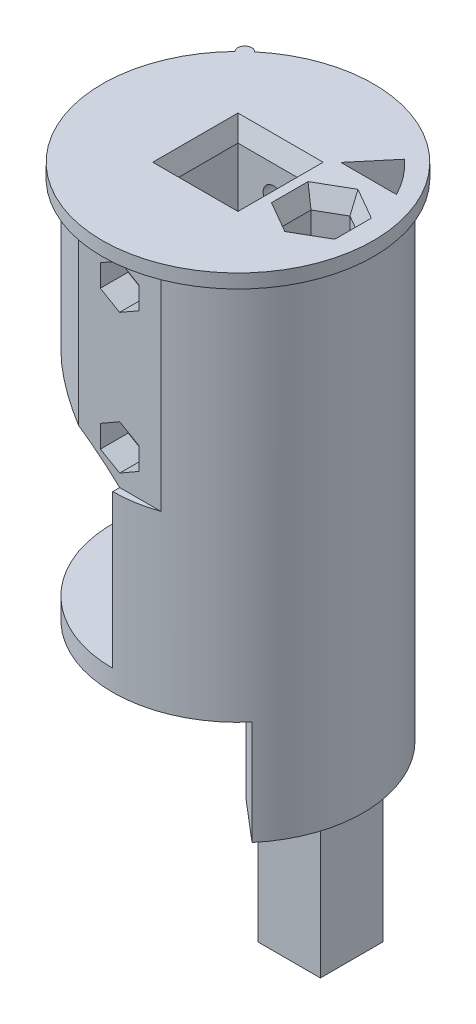
from build123d import *
from build123d.topology import SkipClean

# Parameters (mm, degrees)
SKETCH_1_R          = 18
EXTRUDE_1_DEPTH     = 55
SKETCH_2_R          = 19.5
EXTRUDE_2_DEPTH     = 2
SKETCH_3_W          = 10.25
SKETCH_3_H          = 10.25
CUT_EXTRUDE_1_DEPTH = 40
EXTRUDE_START       = 15
EXTRUDE_3_DEPTH     = 15
BOSS_EXTRUDE1_START = 20
SKETCH1_R           = 18
BOSS_EXTRUDE1_DEPTH = 20
BOSS_EXTRUDE2_START = 7
SKETCH3_R           = 18
BOSS_EXTRUDE2_DEPTH = 7
SKETCH4_W           = 10.2
SKETCH4_H           = 10.2
CUT_EXTRUDE2_DEPTH  = 27
CUT_EXTRUDE4_DEPTH  = 25
BOSS_EXTRUDE3_DEPTH = 3
SKETCH9_W           = 36
SKETCH9_H           = 22
CUT_EXTRUDE5_DEPTH  = 8
SKETCH10_R          = 3.7
SKETCH10_W          = 3
SKETCH10_H          = 2
CUT_EXTRUDE6_DEPTH  = 10
SKETCH11_R          = 2
CUT_EXTRUDE7_DEPTH  = 102
SKETCH15_R          = 18
CUT_EXTRUDE9_DEPTH  = 27
CUT_EXTRUDE11_DEPTH = 30
SKETCH18_R          = 1.5
CUT_EXTRUDE12_DEPTH = 71.437915926
SKETCH19_R          = 3
CUT_EXTRUDE13_DEPTH = 3
BOSS_EXTRUDE5_DEPTH = 22
CUT_EXTRUDE16_DEPTH = 4
CUT_EXTRUDE17_DEPTH = 25.4
CUT_EXTRUDE18_DEPTH = 71.437915926
FILLET2_R           = 5
SKETCH30_W          = 18.8
SKETCH30_H          = 10
CUT_EXTRUDE20_DEPTH = 3
CHAMFER1_SIZE       = 1
CHAMFER1_SIZE2      = 2.747477419
CHAMFER2_SIZE       = 1
CHAMFER2_SIZE2      = 2.747477419
BOSS_EXTRUDE7_START = 20
SKETCH37_W          = 9
SKETCH37_H          = 9
SKETCH37_R          = 2
BOSS_EXTRUDE7_DEPTH = 20
CUT_EXTRUDE22_DEPTH = 15
CUT_EXTRUDE23_DEPTH = 78.100583655
SKETCH40_W          = 4.363156696
SKETCH40_H          = 4.363156696
CUT_EXTRUDE24_DEPTH = 10
FILLET7_R           = 6
BOSS_EXTRUDE8_DEPTH = 2
CUT_EXTRUDE25_DEPTH = 12


with BuildPart() as part:
    # Эскиз1 → Бобышка-Вытянуть1 (new body)
    with BuildSketch(Plane(origin=(0, 0, 0), x_dir=(1, 0, 0), z_dir=(0, 1, 0))):
        with Locations(Location((0, 0, 0), (0, 0, 270))):
            Circle(SKETCH_1_R)
    extrude(amount=EXTRUDE_1_DEPTH)

    # Эскиз2 → Бобышка-Вытянуть2 (add)
    with BuildSketch(Plane(origin=(0, 55, 0), x_dir=(1, 0, 0), z_dir=(0, 1, 0))):
        with Locations(Location((0, 0, 0), (0, 0, 270))):
            Circle(SKETCH_2_R)
    extrude(amount=EXTRUDE_2_DEPTH)

    # Эскиз3 → Вырез-Вытянуть1 (cut)
    with BuildSketch(Plane(origin=(0, 57, 0), x_dir=(1, 0, 0), z_dir=(0, 1, 0))):
        Rectangle(SKETCH_3_W, SKETCH_3_H)
    extrude(amount=-CUT_EXTRUDE_1_DEPTH, mode=Mode.SUBTRACT)

    # Эскиз4 → Бобышка-Вытянуть3 (add)
    with SkipClean():  # the faces are left unmerged after this step: merging them gives an invalid solid
        with BuildSketch(Plane.XZ.offset(EXTRUDE_START)):
            with BuildLine():
                Line((5.142300877, -6.128355545), (11.570176974, -13.788799976))
                ThreePointArc((11.570176974, -13.788799976), (17.937391115, -1.5), (13.69961987, 11.675633406))
                Line((13.69961987, 11.675633406), (5.142300877, 4.38257561))
                Line((5.142300877, 4.38257561), (5.142300877, -6.128355545))
            make_face()
        extrude(amount=-EXTRUDE_3_DEPTH)

    # Sketch1 → Boss-Extrude1 (add)
    with BuildSketch(Plane.XZ.offset(15).offset(BOSS_EXTRUDE1_START)):
        with Locations(Location((0, 0, 0), (0, 0, 270))):
            Circle(SKETCH1_R)
    extrude(amount=-BOSS_EXTRUDE1_DEPTH)

    # Sketch3 → Boss-Extrude2 (add)
    with BuildSketch(Plane.XZ.offset(35).offset(BOSS_EXTRUDE2_START)):
        with Locations(Location((0, 0, 0), (0, 0, 270))):
            Circle(SKETCH3_R)
    extrude(amount=-BOSS_EXTRUDE2_DEPTH)

    # Sketch4 → Cut-Extrude2 (cut)
    with BuildSketch(Plane.XZ.offset(42)):
        Rectangle(SKETCH4_W, SKETCH4_H)
    extrude(amount=-CUT_EXTRUDE2_DEPTH, mode=Mode.SUBTRACT)

    # Sketch6 → Cut-Extrude4 (cut)
    with BuildSketch(Plane.XZ):
        with BuildLine():
            Line((0, 18), (0, -18))
            ThreePointArc((0, -18), (-18, 0), (0, 18))
        make_face()
    extrude(amount=-CUT_EXTRUDE4_DEPTH, mode=Mode.SUBTRACT)

    # Sketch8 → Boss-Extrude3 (add)
    with BuildSketch(Plane.XZ):
        with BuildLine():
            Line((0, -18), (0, 18))
            ThreePointArc((0, 18), (-18, 0), (0, -18))
        make_face()
    extrude(amount=-BOSS_EXTRUDE3_DEPTH)

    # Sketch9 → Cut-Extrude5 (cut)
    with BuildSketch(Plane.ZY):
        with Locations((0, 14)):
            Rectangle(SKETCH9_W, SKETCH9_H)
    extrude(amount=-CUT_EXTRUDE5_DEPTH, mode=Mode.SUBTRACT)

    # Sketch10 → Cut-Extrude6 (cut)
    with BuildSketch(Plane.XZ):
        with Locations(Location((0, 0, 0), (0, 0, 270))):
            Circle(SKETCH10_R)
        with Locations((0, 7.7)):
            Rectangle(SKETCH10_W, SKETCH10_H)
    extrude(amount=-CUT_EXTRUDE6_DEPTH, mode=Mode.SUBTRACT)

    # Sketch11 → Cut-Extrude7 (cut)
    with BuildSketch(Plane.XZ.offset(42)):
        with Locations(Location((12, 0, 0), (0, 0, 270))):
            Circle(SKETCH11_R)
    extrude(amount=-CUT_EXTRUDE7_DEPTH, mode=Mode.SUBTRACT)

    # Sketch15 → Cut-Extrude9 (cut)
    with BuildSketch(Plane.XZ.offset(42)):
        with Locations(Location((0, 0, 0), (0, 0, 310))):
            Circle(SKETCH15_R)
    extrude(amount=-CUT_EXTRUDE9_DEPTH, mode=Mode.SUBTRACT)

    # Sketch17 → Cut-Extrude11 (cut)
    with BuildSketch(Plane.XZ.offset(-25)):
        with BuildLine():
            Line((5.916079783, -17), (-5.916079783, -17))
            ThreePointArc((-5.916079783, -17), (0, -18), (5.916079783, -17))
        make_face()
        with BuildLine():
            Line((5.916079783, 17), (-5.916079783, 17))
            ThreePointArc((-5.916079783, 17), (0, 18), (5.916079783, 17))
        make_face()
    extrude(amount=-CUT_EXTRUDE11_DEPTH, mode=Mode.SUBTRACT)

    # Sketch18 → Cut-Extrude12 (cut, through all)
    with BuildSketch(Plane.XY.offset(-17)):
        with Locations(Location((0, 30, 0), (0, 0, 180))):
            Circle(SKETCH18_R)
        with Locations(Location((0, 50, 0), (0, 0, 180))):
            Circle(SKETCH18_R)
    extrude(amount=CUT_EXTRUDE12_DEPTH, mode=Mode.SUBTRACT)

    # Sketch19 → Cut-Extrude13 (cut)
    with BuildSketch(Plane.XY.offset(-17)):
        with Locations((0, 30)):
            Circle(SKETCH19_R)
        with Locations((0, 50)):
            Circle(SKETCH19_R)
    extrude(amount=CUT_EXTRUDE13_DEPTH, mode=Mode.SUBTRACT)

    # Sketch23 → Boss-Extrude5 (add)
    with BuildSketch(Plane(origin=(0, 3, 0), x_dir=(1, 0, 0), z_dir=(0, 1, 0))):
        with BuildLine():
            Line((0, -14.4), (8, -14.4))
            Line((8, -14.4), (8, -16.124515497))
            ThreePointArc((8, -16.124515497), (4.108449894, -17.524857759), (0, -18))
            Line((0, -18), (0, -14.4))
        make_face()
        with BuildLine():
            Line((0, 14.4), (8, 14.4))
            Line((8, 14.4), (8, 16.124515497))
            ThreePointArc((8, 16.124515497), (4.108449894, 17.524857759), (0, 18))
            Line((0, 18), (0, 14.4))
        make_face()
    extrude(amount=BOSS_EXTRUDE5_DEPTH)

    # Sketch25 → Cut-Extrude16 (cut)
    with BuildSketch(Plane.XY.offset(17)):
        Polygon((2.771281292, 28.4), (2.771281292, 31.6), (0, 33.2), (-2.771281292, 31.6), (-2.771281292, 28.4), (0, 26.8), align=None)
        Polygon((-2.782126929, 48.418933983), (-0.021820128, 46.800074394), (2.760306801, 48.381140412), (2.782126929, 51.581066017), (0.021820128, 53.199925606), (-2.760306801, 51.618859588), align=None)
    extrude(amount=-CUT_EXTRUDE16_DEPTH, mode=Mode.SUBTRACT)

    # Sketch26 → Cut-Extrude17 (cut)
    with BuildSketch(Plane(origin=(0, 57, 0), x_dir=(1, 0, 0), z_dir=(0, 1, 0))):
        Polygon((8.449295844, -2.05), (12, -4.1), (15.550704156, -2.05), (15.550704156, 2.05), (12, 4.1), (8.449295844, 2.05), align=None)
    extrude(amount=-CUT_EXTRUDE17_DEPTH, mode=Mode.SUBTRACT)

    # Sketch27 → Cut-Extrude18 (cut, through all)
    with BuildSketch(Plane.XY.offset(17)):
        with BuildLine():
            Line((-20, 36.547005384), (-20, 25))
            Line((-20, 25), (0, 25))
            ThreePointArc((0, 25), (-9.324199199, 31.944024015), (-20, 36.547005384))
        make_face()
    extrude(amount=-CUT_EXTRUDE18_DEPTH, mode=Mode.SUBTRACT)

    # Fillet2
    fillet2_edges = [part.edges().sort_by_distance(p)[0] for p in [
        (8, 14, -14.4),
        (8, 14, 14.4),
    ]]
    fillet(fillet2_edges, radius=FILLET2_R)

    # Sketch30 → Cut-Extrude20 (cut)
    with BuildSketch(Plane.ZY.offset(-8)):
        with Locations((0, 8)):
            Rectangle(SKETCH30_W, SKETCH30_H)
    extrude(amount=-CUT_EXTRUDE20_DEPTH, mode=Mode.SUBTRACT)

    # Chamfer1
    chamfer1_edges = [part.edges().sort_by_distance(p)[0] for p in [
        (5.125, 57, 0),
        (0, 57, -5.125),
        (-5.125, 57, 0),
        (0, 57, 5.125),
    ]]
    chamfer1_side = [part.faces().sort_by_distance(p)[0] for p in [
        (0, 57, -18.948456711),
    ]]
    chamfer(chamfer1_edges, length=CHAMFER1_SIZE, length2=CHAMFER1_SIZE2, reference=chamfer1_side[0])

    # Chamfer2
    chamfer2_edges = [part.edges().sort_by_distance(p)[0] for p in [
        (8.449295844, 57, 0),
        (10.224647922, 57, 3.075),
        (13.775352078, 57, 3.075),
        (15.550704156, 57, 0),
        (13.775352078, 57, -3.075),
        (10.224647922, 57, -3.075),
    ]]
    chamfer2_side = [part.faces().sort_by_distance(p)[0] for p in [
        (6.676543289, 57, 0),
    ]]
    chamfer(chamfer2_edges, length=CHAMFER2_SIZE, length2=CHAMFER2_SIZE2, reference=chamfer2_side[0])

    # Sketch37 → Boss-Extrude7 (add)
    with BuildSketch(Plane.XZ.offset(15).offset(BOSS_EXTRUDE7_START)):
        with Locations((10.978822628, -0.872889968)):
            Rectangle(SKETCH37_W, SKETCH37_H)
        with Locations(Location((12, 0, 0), (0, 0, 270))):
            Circle(SKETCH37_R, mode=Mode.SUBTRACT)
    extrude(amount=-BOSS_EXTRUDE7_DEPTH)

    # Sketch38 → Cut-Extrude22 (cut)
    with BuildSketch(Plane.XZ.offset(15)):
        with BuildLine():
            Line((5.142300877, -6.128355545), (5.142300877, 4.38257561))
            ThreePointArc((5.142300877, 4.38257561), (5.978822628, -0.872889968), (5.142300877, -6.128355545))
        make_face()
    extrude(amount=-CUT_EXTRUDE22_DEPTH, mode=Mode.SUBTRACT)

    # Sketch39 → Cut-Extrude23 (cut, through all)
    with BuildSketch(Plane.XZ.offset(15)):
        with BuildLine():
            Line((7.420733648, -7.372889968), (15.420733648, -7.372889968))
            ThreePointArc((15.420733648, -7.372889968), (13.728515389, -10.030415688), (11.598853111, -12.352178848))
            Line((11.598853111, -12.352178848), (7.420733648, -7.372889968))
        make_face()
    extrude(amount=-CUT_EXTRUDE23_DEPTH, mode=Mode.SUBTRACT)

    # Sketch40 → Cut-Extrude24 (cut)
    with BuildSketch(Plane(origin=(0, 3, 0), x_dir=(1, 0, 0), z_dir=(0, 1, 0))):
        with Locations((9.602311996, 9.554468316)):
            Rectangle(SKETCH40_W, SKETCH40_H)
    extrude(amount=CUT_EXTRUDE24_DEPTH, mode=Mode.SUBTRACT)

    # Fillet7
    fillet7_edges = [part.edges().sort_by_distance(p)[0] for p in [
        (5.142300877, -7.5, 4.38257561),
        (5.142300877, -7.5, -6.128355545),
    ]]
    fillet(fillet7_edges, radius=FILLET7_R)

    # Sketch41 → Boss-Extrude8 (add)
    with BuildSketch(Plane(origin=(0, 57, 0), x_dir=(1, 0, 0), z_dir=(0, 1, 0))):
        with BuildLine():
            Line((-13.998504433, 13.575414308), (-12.534358389, 14.937866641))
            ThreePointArc((-12.534358389, 14.937866641), (-13.947657578, 14.988713497), (-13.998504433, 13.575414308))
        make_face()
    extrude(amount=-BOSS_EXTRUDE8_DEPTH)

    # Sketch42 → Cut-Extrude25 (cut)
    with BuildSketch(Plane.XZ.offset(-13)):
        Polygon((8, -8.063232724), (7.420733648, -11.736046664), (11.081856822, -11.736046664), align=None)
    extrude(amount=-CUT_EXTRUDE25_DEPTH, mode=Mode.SUBTRACT)


solid = part.part
